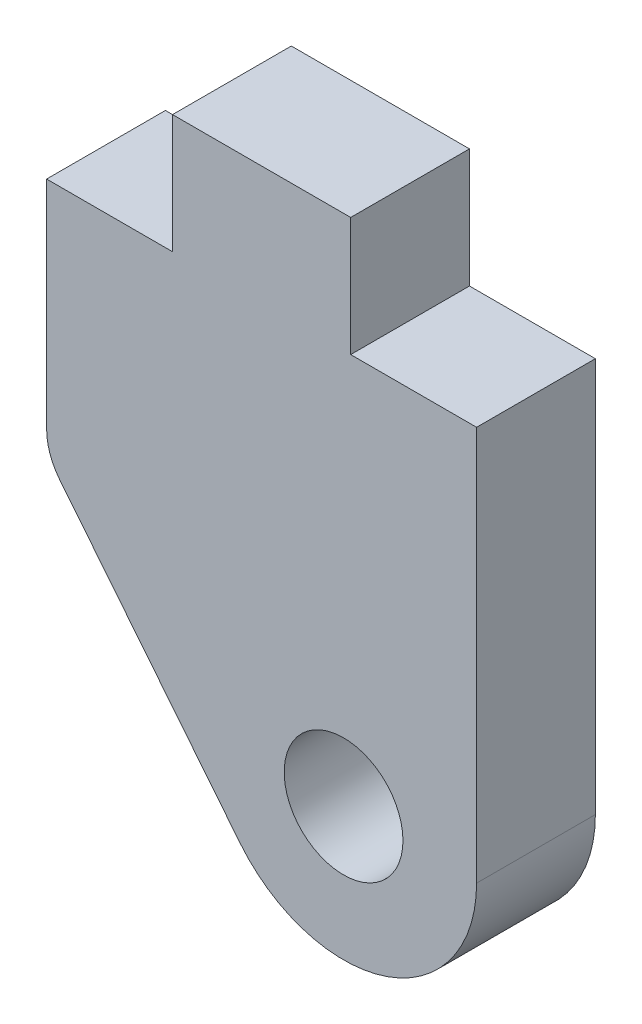
from build123d import *

# Parameters (mm, degrees)
SKETCH1_R           = 1.5875
BOSS_EXTRUDE1_DEPTH = 1.5875


with BuildPart() as part:
    # Sketch1 → Boss-Extrude1 (new body, symmetric)
    with BuildSketch(Plane.XY):
        with BuildLine():
            Line((-5.74675, 0), (-5.74675, -5.791392014))
            ThreePointArc((-5.74675, -5.791392014), (-5.65674567, -6.318329362), (-5.396938386, -6.785516609))
            Line((-5.396938386, -6.785516609), (-0.581671984, -12.780539093))
            ThreePointArc((-0.581671984, -12.780539093), (3.37108966, -13.9080903), (5.74675, -10.5537))
            Line((5.74675, -10.5537), (5.74675, 0))
            Line((5.74675, 0), (2.38125, 0))
            Line((2.38125, 0), (2.38125, 3.175))
            Line((2.38125, 3.175), (-2.38125, 3.175))
            Line((-2.38125, 3.175), (-2.38125, 0))
            Line((-2.38125, 0), (-5.74675, 0))
        make_face()
        with Locations((2.19075, -10.5537)):
            Circle(SKETCH1_R, mode=Mode.SUBTRACT)
    extrude(amount=BOSS_EXTRUDE1_DEPTH, both=True)


solid = part.part
